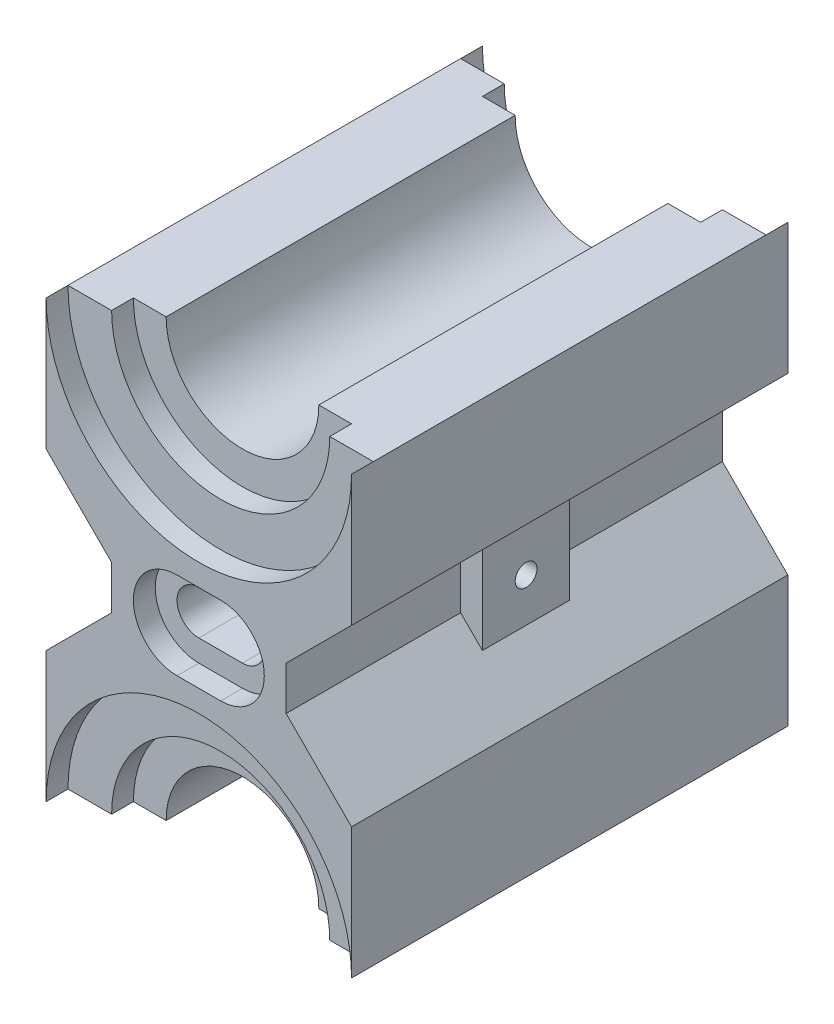
from build123d import *

# Parameters (mm, degrees)
BOSS_EXTRUDE1_DEPTH = 100
BOSS_EXTRUDE2_DEPTH = 95
CUT_EXTRUDE1_DEPTH  = 5
BOSS_EXTRUDE5_DEPTH = 85
CUT_EXTRUDE4_DEPTH  = 5
BOSS_EXTRUDE6_DEPTH = 60
CUT_EXTRUDE5_DEPTH  = 40
SKETCH11_R          = 2.5
CUT_EXTRUDE6_DEPTH  = 15
SKETCH12_R          = 2.5
CUT_EXTRUDE7_DEPTH  = 15
CUT_EXTRUDE8_DEPTH  = 5
CUT_EXTRUDE9_DEPTH  = 30
CUT_EXTRUDE10_DEPTH = 5
CUT_EXTRUDE11_DEPTH = 30


with BuildPart() as part:
    # Sketch1 → Boss-Extrude1 (new body)
    with BuildSketch(Plane.XY):
        with BuildLine():
            Line((-70, 0), (-70, 30))
            Line((-70, 30), (-55, 45))
            Line((-55, 45), (-55, 55))
            Line((-55, 55), (-70, 70))
            Line((-70, 70), (-70, 100))
            ThreePointArc((-70, 100), (-35, 65), (0, 100))
            Line((0, 100), (0, 70))
            Line((0, 70), (-15, 55))
            Line((-15, 55), (-15, 45))
            Line((-15, 45), (0, 30))
            Line((0, 30), (0, 0))
            ThreePointArc((0, 0), (-35, 35), (-70, 0))
        make_face()
    extrude(amount=BOSS_EXTRUDE1_DEPTH)

    # Sketch2 → Boss-Extrude2 (add)
    with BuildSketch(Plane(origin=(0, 0, 0), x_dir=(-1, 0, 0), z_dir=(0, 0, -1))):
        with BuildLine():
            Line((0, 100), (10, 100))
            ThreePointArc((10, 100), (35, 75), (60, 100))
            Line((60, 100), (70, 100))
            ThreePointArc((70, 100), (35, 65), (0, 100))
        make_face()
        with BuildLine():
            Line((0, 0), (10, 0))
            ThreePointArc((10, 0), (35, 25), (60, 0))
            Line((60, 0), (70, 0))
            ThreePointArc((70, 0), (35, 35), (0, 0))
        make_face()
    extrude(amount=-BOSS_EXTRUDE2_DEPTH)

    # Sketch3 → Cut-Extrude1 (cut)
    with BuildSketch(Plane(origin=(0, 0, 0), x_dir=(-1, 0, 0), z_dir=(0, 0, -1))):
        with BuildLine():
            Line((0, 100), (10, 100))
            ThreePointArc((10, 100), (35, 75), (60, 100))
            Line((60, 100), (70, 100))
            ThreePointArc((70, 100), (35, 65), (0, 100))
        make_face()
        with BuildLine():
            Line((60, 0), (70, 0))
            ThreePointArc((70, 0), (35, 35), (0, 0))
            Line((0, 0), (10, 0))
            ThreePointArc((10, 0), (35, 25), (60, 0))
        make_face()
    extrude(amount=-CUT_EXTRUDE1_DEPTH, mode=Mode.SUBTRACT)

    # Sketch4 → Boss-Extrude5 (add)
    with BuildSketch(Plane(origin=(0, 0, 5), x_dir=(-1, 0, 0), z_dir=(0, 0, -1))):
        with BuildLine():
            Line((10, 100), (17.5, 100))
            ThreePointArc((17.5, 100), (35, 82.5), (52.5, 100))
            Line((52.5, 100), (60, 100))
            ThreePointArc((60, 100), (35, 75), (10, 100))
        make_face()
        with BuildLine():
            Line((10, 0), (17.5, 0))
            ThreePointArc((17.5, 0), (35, 17.5), (52.5, 0))
            Line((52.5, 0), (60, 0))
            ThreePointArc((60, 0), (35, 25), (10, 0))
        make_face()
    extrude(amount=-BOSS_EXTRUDE5_DEPTH)

    # Sketch7 → Cut-Extrude4 (cut)
    with BuildSketch(Plane(origin=(0, 0, 5), x_dir=(-1, 0, 0), z_dir=(0, 0, -1))):
        with BuildLine():
            ThreePointArc((52.5, 100), (35, 82.5), (17.5, 100))
            Line((17.5, 100), (10, 100))
            ThreePointArc((10, 100), (35, 75), (60, 100))
            Line((60, 100), (52.5, 100))
        make_face()
        with BuildLine():
            Line((10, 0), (17.5, 0))
            ThreePointArc((17.5, 0), (35, 17.5), (52.5, 0))
            Line((52.5, 0), (60, 0))
            ThreePointArc((60, 0), (35, 25), (10, 0))
        make_face()
    extrude(amount=-CUT_EXTRUDE4_DEPTH, mode=Mode.SUBTRACT)

    # Sketch9 → Boss-Extrude6 (add)
    with BuildSketch(Plane(origin=(0, 0, 0), x_dir=(-1, 0, 0), z_dir=(0, 0, -1))):
        Polygon((10, 40), (15, 45), (15, 55), (10, 60), align=None)
        Polygon((60, 60), (55, 55), (55, 45), (60, 40), align=None)
    extrude(amount=-BOSS_EXTRUDE6_DEPTH)

    # Sketch10 → Cut-Extrude5 (cut)
    with BuildSketch(Plane(origin=(0, 0, 0), x_dir=(-1, 0, 0), z_dir=(0, 0, -1))):
        Polygon((10, 40), (15, 45), (15, 55), (10, 60), align=None)
        Polygon((60, 40), (55, 45), (55, 55), (60, 60), align=None)
    extrude(amount=-CUT_EXTRUDE5_DEPTH, mode=Mode.SUBTRACT)

    # Sketch11 → Cut-Extrude6 (cut)
    with BuildSketch(Plane(origin=(-10, 0, 0), x_dir=(0, 0, -1), z_dir=(1, 0, 0))):
        with Locations((-50, 50)):
            Circle(SKETCH11_R)
    extrude(amount=-CUT_EXTRUDE6_DEPTH, mode=Mode.SUBTRACT)

    # Sketch12 → Cut-Extrude7 (cut)
    with BuildSketch(Plane.ZY.offset(60)):
        with Locations((50, 50)):
            Circle(SKETCH12_R)
    extrude(amount=-CUT_EXTRUDE7_DEPTH, mode=Mode.SUBTRACT)

    # Sketch13 → Cut-Extrude8 (cut)
    with BuildSketch(Plane(origin=(0, 0, 0), x_dir=(-1, 0, 0), z_dir=(0, 0, -1))):
        with BuildLine():
            Line((30, 60), (40, 60))
            ThreePointArc((40, 60), (50, 50), (40, 40))
            Line((40, 40), (30, 40))
            ThreePointArc((30, 40), (20, 50), (30, 60))
        make_face()
    extrude(amount=-CUT_EXTRUDE8_DEPTH, mode=Mode.SUBTRACT)

    # Sketch14 → Cut-Extrude9 (cut)
    with BuildSketch(Plane(origin=(0, 0, 5), x_dir=(-1, 0, 0), z_dir=(0, 0, -1))):
        with BuildLine():
            Line((30, 55), (40, 55))
            ThreePointArc((40, 55), (45, 50), (40, 45))
            Line((40, 45), (30, 45))
            ThreePointArc((30, 45), (25, 50), (30, 55))
        make_face()
    extrude(amount=-CUT_EXTRUDE9_DEPTH, mode=Mode.SUBTRACT)

    # Sketch15 → Cut-Extrude10 (cut)
    with BuildSketch(Plane.XY.offset(100)):
        with BuildLine():
            Line((-40, 60), (-30, 60))
            ThreePointArc((-30, 60), (-20, 50), (-30, 40))
            Line((-30, 40), (-40, 40))
            ThreePointArc((-40, 40), (-50, 50), (-40, 60))
        make_face()
    extrude(amount=-CUT_EXTRUDE10_DEPTH, mode=Mode.SUBTRACT)

    # Sketch16 → Cut-Extrude11 (cut)
    with BuildSketch(Plane.XY.offset(95)):
        with BuildLine():
            Line((-40, 55), (-30, 55))
            ThreePointArc((-30, 55), (-25, 50), (-30, 45))
            Line((-30, 45), (-40, 45))
            ThreePointArc((-40, 45), (-45, 50), (-40, 55))
        make_face()
    extrude(amount=-CUT_EXTRUDE11_DEPTH, mode=Mode.SUBTRACT)


solid = part.part
